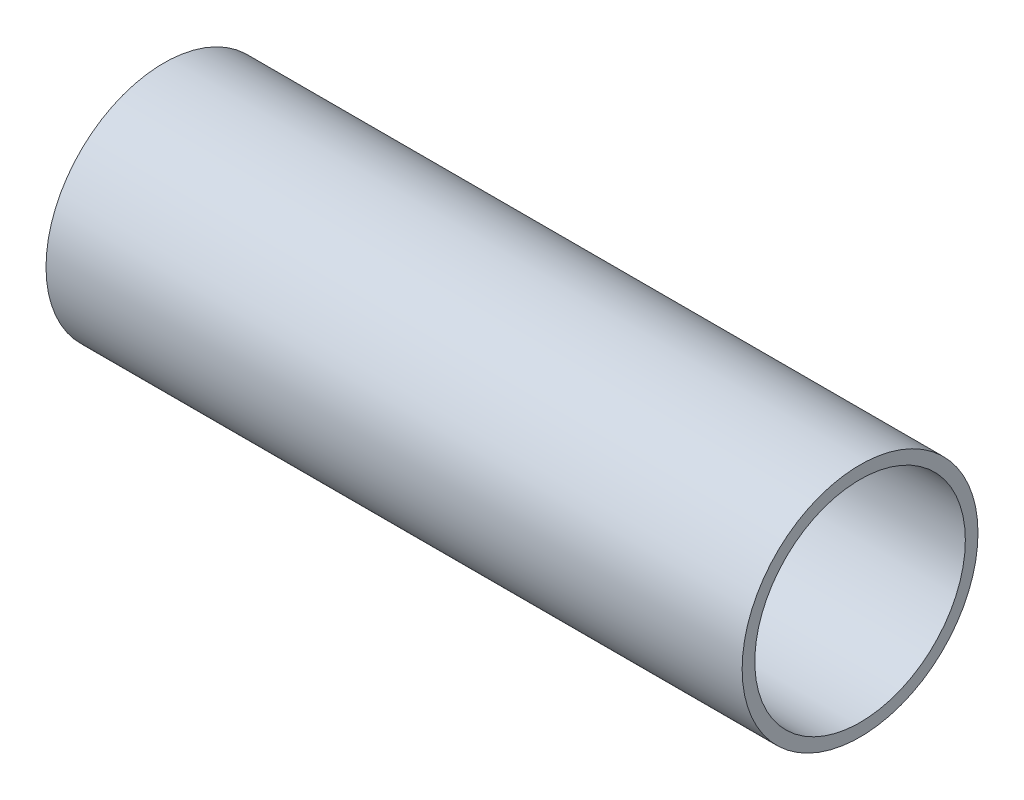
from build123d import *

# Parameters (mm, degrees)
SKETCH2_R           = 93.17284
BOSS_EXTRUDE1_DEPTH = 550
SKETCH3_R           = 83.17284
CUT_EXTRUDE1_DEPTH  = 551


with BuildPart() as part:
    # Sketch2 → Boss-Extrude1 (new body)
    with BuildSketch(Plane(origin=(0, 0, 0), x_dir=(0, 0, -1), z_dir=(1, 0, 0))):
        Circle(SKETCH2_R)
    extrude(amount=BOSS_EXTRUDE1_DEPTH)

    # Sketch3 → Cut-Extrude1 (cut, through all)
    with BuildSketch(Plane(origin=(550, 0, 0), x_dir=(0, 0, -1), z_dir=(1, 0, 0))):
        Circle(SKETCH3_R)
    extrude(amount=-CUT_EXTRUDE1_DEPTH, mode=Mode.SUBTRACT)


solid = part.part
